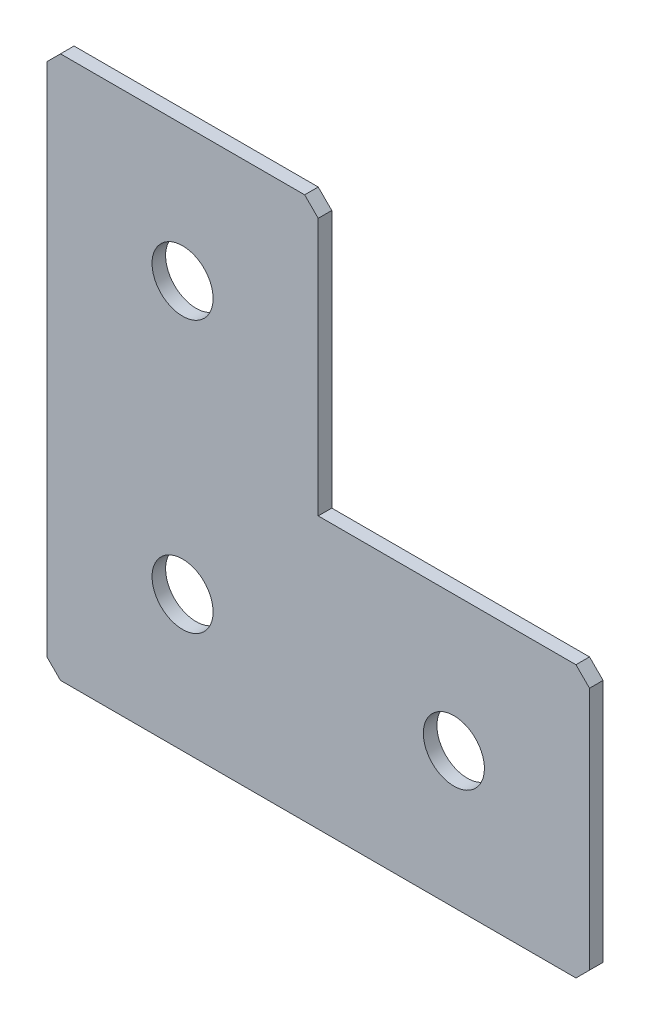
from build123d import *

# Parameters (mm, degrees)
EXTRUDE_1_DEPTH   = 2
HOLE_WIZARD_M81_D = 9
CHAMFER_1_SIZE    = 2


with BuildPart() as part:
    # Эскиз1 → Бобышка-Вытянуть1 (new body)
    with BuildSketch(Plane(origin=(0, 0, 0), x_dir=(1, 0, 0), z_dir=(0, 0, -1))):
        Polygon((0, 0), (0, 80), (80, 80), (80, 40), (40, 40), (40, 0), align=None)
    extrude(amount=EXTRUDE_1_DEPTH)

    # Отверстие с зазором M81 (through all)
    with Locations(Plane(origin=(0, 0, -2), x_dir=(1, 0, 0), z_dir=(0, 0, -1))):
        with Locations((20, 60), (20, 20), (60, 60)):
            Hole(HOLE_WIZARD_M81_D / 2)

    # Фаска1
    chamfer_1_edges = [part.edges().sort_by_distance(p)[0] for p in [
        (0, 0, -1),
        (0, -80, -1),
        (80, -80, -1),
        (80, -40, -1),
        (40, 0, -1),
    ]]
    chamfer(chamfer_1_edges, length=CHAMFER_1_SIZE)


solid = part.part
